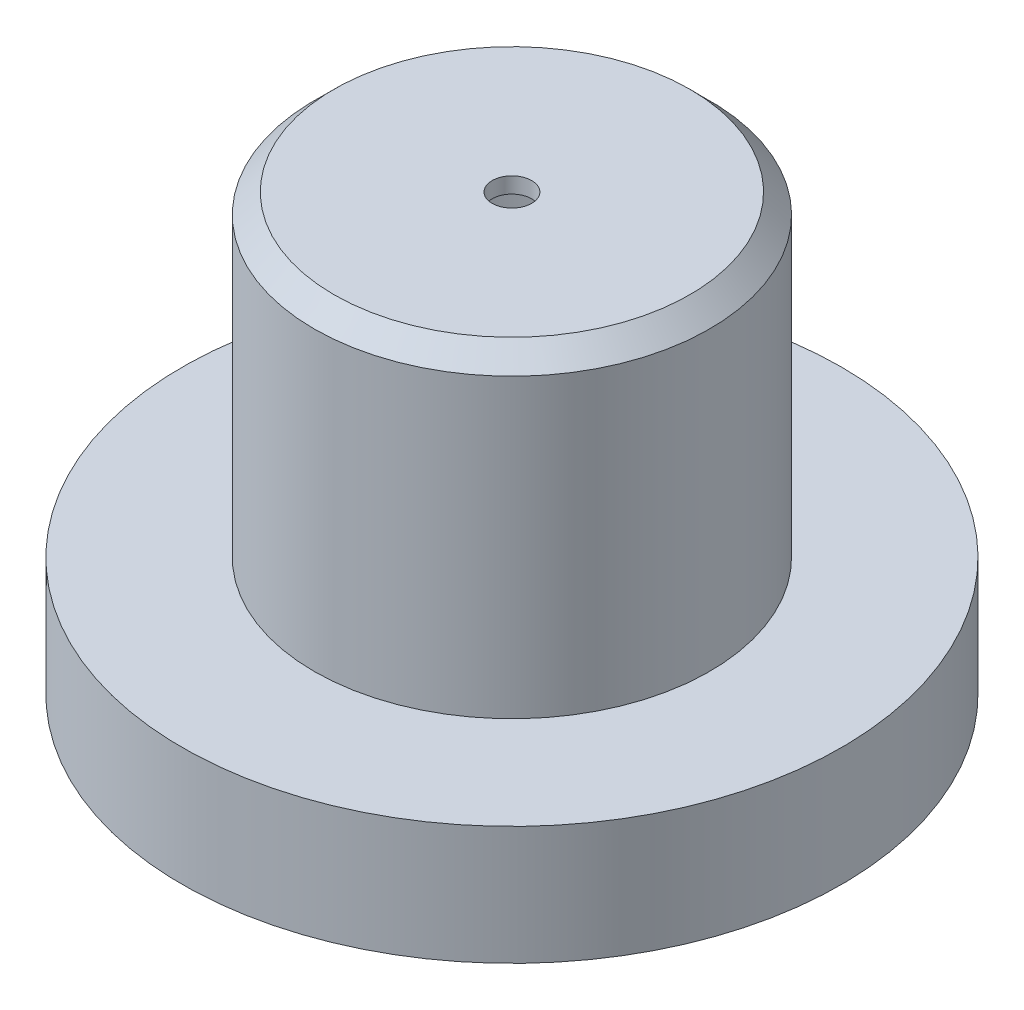
from build123d import *

# Parameters (mm, degrees)
BOSS_EXTRUDE1_DEPTH = 100
SKETCH3_R           = 50
BOSS_EXTRUDE3_DEPTH = 80
CHAMFER1_SIZE       = 5
FILLET1_R           = 1
SKETCH4_R           = 5
CUT_EXTRUDE1_DEPTH  = 20
SKETCH5_R           = 15
SKETCH5_R_2         = 2.5
SKETCH5_W           = 60
SKETCH5_H           = 10
SKETCH5_W_2         = 50
CUT_EXTRUDE2_DEPTH  = 20
SKETCH6_W           = 150
SKETCH6_H           = 200
CUT_EXTRUDE3_DEPTH  = 181
SKETCH7_R           = 83.3335
BOSS_EXTRUDE4_DEPTH = 30
SHELL1_T            = -4
SKETCH10_R          = 5
CUT_EXTRUDE4_DEPTH  = 209


with BuildPart() as part:
    # Sketch2 → Boss-Extrude1 (new, symmetric)
    with BuildSketch(Plane.XY):
        with BuildLine():
            Line((-75, 50), (-70, 50))
            ThreePointArc((-70, 50), (-65, 45), (-60, 50))
            Line((-60, 50), (-35, 50))
            Line((-35, 50), (-25, 50))
            Line((-25, 50), (25, 50))
            Line((25, 50), (35, 50))
            Line((35, 50), (60, 50))
            ThreePointArc((60, 50), (65, 45), (70, 50))
            Line((70, 50), (75, 50))
            Line((75, 50), (75, 15))
            ThreePointArc((75, 15), (70.980762114, 0), (75, -15))
            Line((75, -15), (75, -50))
            Line((75, -50), (70, -50))
            ThreePointArc((70, -50), (65, -45), (60, -50))
            Line((60, -50), (35, -50))
            ThreePointArc((35, -50), (30, -45), (25, -50))
            Line((25, -50), (-25, -50))
            ThreePointArc((-25, -50), (-30, -45), (-35, -50))
            Line((-35, -50), (-60, -50))
            ThreePointArc((-60, -50), (-65, -45), (-70, -50))
            Line((-70, -50), (-75, -50))
            Line((-75, -50), (-75, -15))
            ThreePointArc((-75, -15), (-70.980762114, 0), (-75, 15))
            Line((-75, 15), (-75, 50))
        make_face()
    extrude(amount=BOSS_EXTRUDE1_DEPTH, both=True)

    # Sketch3 → Boss-Extrude3 (add)
    with BuildSketch(Plane(origin=(0, 50, 0), x_dir=(1, 0, 0), z_dir=(0, 1, 0))):
        with Locations(Location((0, 0, 0), (0, 0, 90))):
            Circle(SKETCH3_R)
    extrude(amount=BOSS_EXTRUDE3_DEPTH)

    # Chamfer1
    chamfer1_edges = [part.edges().sort_by_distance(p)[0] for p in [
        (0, 130, 50),
    ]]
    chamfer(chamfer1_edges, length=CHAMFER1_SIZE)

    # Fillet1
    fillet1_edges = [part.edges().sort_by_distance(p)[0] for p in [
        (-75, -50, 0),
        (-75, 50, 0),
        (75, 50, 0),
        (75, -50, 0),
    ]]
    fillet(fillet1_edges, radius=FILLET1_R)

    # Sketch4 → Cut-Extrude1 (cut)
    with BuildSketch(Plane.XZ.offset(50)):
        with Locations(Location((-47.5, 80, 0), (0, 0, 270))):
            Circle(SKETCH4_R)
        with Locations(Location((47.5, 80, 0), (0, 0, 270))):
            Circle(SKETCH4_R)
        with Locations(Location((47.5, 40, 0), (0, 0, 270))):
            Circle(SKETCH4_R)
        with Locations(Location((47.5, 0, 0), (0, 0, 270))):
            Circle(SKETCH4_R)
        with Locations(Location((47.5, -40, 0), (0, 0, 270))):
            Circle(SKETCH4_R)
        with Locations(Location((47.5, -80, 0), (0, 0, 270))):
            Circle(SKETCH4_R)
        with Locations(Location((-47.5, 40, 0), (0, 0, 270))):
            Circle(SKETCH4_R)
        with Locations(Location((-47.5, 0, 0), (0, 0, 270))):
            Circle(SKETCH4_R)
        with Locations(Location((-47.5, -40, 0), (0, 0, 270))):
            Circle(SKETCH4_R)
        with Locations(Location((-47.5, -80, 0), (0, 0, 270))):
            Circle(SKETCH4_R)
    extrude(amount=-CUT_EXTRUDE1_DEPTH, mode=Mode.SUBTRACT)

    # Sketch5 → Cut-Extrude2 (cut)
    with BuildSketch(Plane(origin=(0, 0, -100), x_dir=(-1, 0, 0), z_dir=(0, 0, -1))):
        with Locations((40, 25)):
            Circle(SKETCH5_R)
        with Locations((35, 25)):
            Circle(SKETCH5_R_2, mode=Mode.SUBTRACT)
        with Locations((45, 25)):
            Circle(SKETCH5_R_2, mode=Mode.SUBTRACT)
        with Locations((-25, -20)):
            Rectangle(SKETCH5_W, SKETCH5_H)
        with Locations((-25, 10)):
            Rectangle(SKETCH5_W_2, SKETCH5_H)
    extrude(amount=-CUT_EXTRUDE2_DEPTH, mode=Mode.SUBTRACT)

    # Sketch6 → Cut-Extrude3 (cut)
    with BuildSketch(Plane(origin=(0, 50, 0), x_dir=(1, 0, 0), z_dir=(0, 1, 0))):
        Rectangle(SKETCH6_W, SKETCH6_H)
    extrude(amount=-CUT_EXTRUDE3_DEPTH, mode=Mode.SUBTRACT)

    # Sketch7 → Boss-Extrude4 (add)
    with BuildSketch(Plane.XZ.offset(-50)):
        with Locations(Location((0, 0, 0), (0, 0, 270))):
            Circle(SKETCH7_R)
    extrude(amount=BOSS_EXTRUDE4_DEPTH)

    # Shell1
    shell1_openings = [part.faces().sort_by_distance(p)[0] for p in [
        (0, 20, 0),
    ]]
    offset(amount=SHELL1_T, openings=shell1_openings, kind=Kind.INTERSECTION)

    # Sketch10 → Cut-Extrude4 (cut)
    with BuildSketch(Plane(origin=(0, 130, 0), x_dir=(1, 0, 0), z_dir=(0, 1, 0))):
        with Locations(Location((0, 0, 0), (0, 0, 270))):
            Circle(SKETCH10_R)
    extrude(amount=-CUT_EXTRUDE4_DEPTH, mode=Mode.SUBTRACT)


solid = part.part
